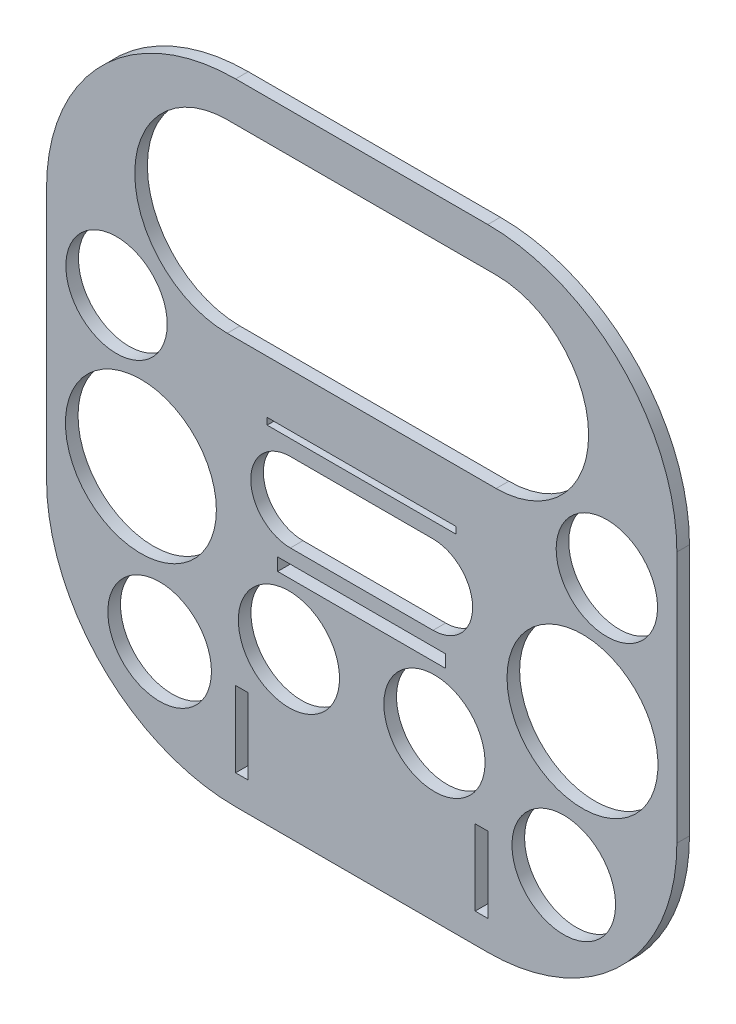
from build123d import *

# Parameters (mm, degrees)
BOSS_EXTRUDE1_DEPTH = 3
SKETCH2_R           = 12.039123234
SKETCH2_R_2         = 12.323940374
SKETCH2_R_3         = 12.062522367
SKETCH2_R_4         = 17.95917031
SKETCH2_W           = 3
SKETCH2_H           = 18
SKETCH2_W_2         = 45
SKETCH2_H_2         = 1.6
SKETCH2_W_3         = 40
SKETCH2_H_3         = 3
CUT_EXTRUDE1_DEPTH  = 10


with BuildPart() as part:
    # Sketch1 → Boss-Extrude1 (new body)
    with BuildSketch(Plane.XY):
        with BuildLine():
            Line((-30, 53.5), (30, 53.5))
            ThreePointArc((30, 53.5), (61.819805153, 40.319805153), (75, 8.5))
            Line((75, 8.5), (75, -51.5))
            ThreePointArc((75, -51.5), (61.819805153, -83.319805153), (30, -96.5))
            Line((30, -96.5), (0.5, -96.5))
            Line((0.5, -96.5), (-0.5, -96.5))
            Line((-0.5, -96.5), (-30, -96.5))
            ThreePointArc((-30, -96.5), (-61.819805153, -83.319805153), (-75, -51.5))
            Line((-75, -51.5), (-75, 8.5))
            ThreePointArc((-75, 8.5), (-61.819805153, 40.319805153), (-30, 53.5))
        make_face()
    extrude(amount=BOSS_EXTRUDE1_DEPTH)

    # Sketch2 → Cut-Extrude1 (cut)
    with BuildSketch(Plane.XY.offset(3)):
        with Locations((-17.315529095, -57.691685277)):
            Circle(SKETCH2_R)
        with Locations((-48.082177359, -71.5)):
            Circle(SKETCH2_R_2)
        with Locations((48.082177359, -71.5)):
            Circle(SKETCH2_R_2)
        with Locations((17.315529095, -57.691685277)):
            Circle(SKETCH2_R)
        with Locations((-58.337726781, -5.217073599)):
            Circle(SKETCH2_R_3)
        with Locations((-52.54111189, -37.626479887)):
            Circle(SKETCH2_R_4)
        with Locations((52.54111189, -37.626479887)):
            Circle(SKETCH2_R_4)
        with Locations((58.337726781, -5.217073599)):
            Circle(SKETCH2_R_3)
        with Locations((-28.5, -80.5)):
            Rectangle(SKETCH2_W, SKETCH2_H)
        with Locations((28.5, -80.5)):
            Rectangle(SKETCH2_W, SKETCH2_H)
        with Locations((0, -13.3)):
            Rectangle(SKETCH2_W_2, SKETCH2_H_2)
        with Locations((0, -41.5)):
            Rectangle(SKETCH2_W_3, SKETCH2_H_3)
        with BuildLine():
            Line((-32, 44.093276202), (32, 44.093276202))
            ThreePointArc((32, 44.093276202), (54, 22.093276202), (32, 0.093276202))
            Line((32, 0.093276202), (-32, 0.093276202))
            ThreePointArc((-32, 0.093276202), (-54, 22.093276202), (-32, 44.093276202))
        make_face()
        with BuildLine():
            Line((-16.972534131, -17.799407518), (16.972534131, -17.799407518))
            ThreePointArc((16.972534131, -17.799407518), (26.395425928, -27.222299315), (16.972534131, -36.645191111))
            Line((16.972534131, -36.645191111), (-16.972534131, -36.645191111))
            ThreePointArc((-16.972534131, -36.645191111), (-26.395425928, -27.222299315), (-16.972534131, -17.799407518))
        make_face()
    extrude(amount=-CUT_EXTRUDE1_DEPTH, mode=Mode.SUBTRACT)


solid = part.part
